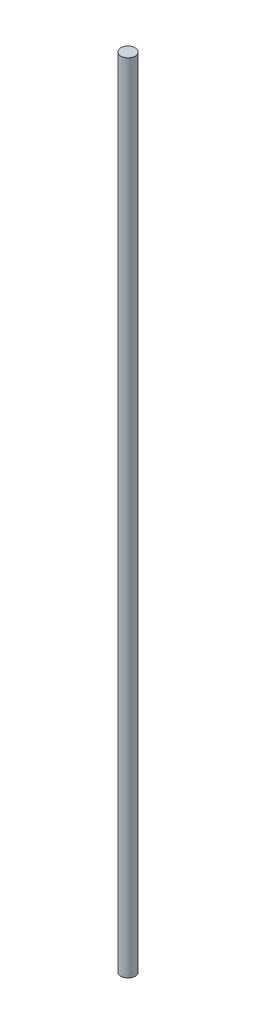
from build123d import *

# Parameters (mm, degrees)
SKETCH1_R           = 4
BOSS_EXTRUDE1_DEPTH = 440


with BuildPart() as part:
    # Sketch1 → Boss-Extrude1 (new body)
    with BuildSketch(Plane(origin=(0, 0, 0), x_dir=(1, 0, 0), z_dir=(0, 1, 0))):
        Circle(SKETCH1_R)
    extrude(amount=BOSS_EXTRUDE1_DEPTH)


solid = part.part
